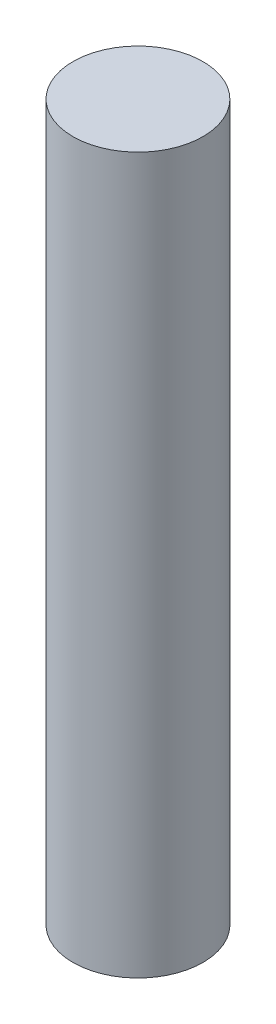
from build123d import *

# Parameters (mm, degrees)
SKETCH1_R           = 3.175
BOSS_EXTRUDE1_DEPTH = 34.925


with BuildPart() as part:
    # Sketch1 → Boss-Extrude1 (new body)
    with BuildSketch(Plane(origin=(0, 0, 0), x_dir=(1, 0, 0), z_dir=(0, 1, 0))):
        Circle(SKETCH1_R)
    extrude(amount=BOSS_EXTRUDE1_DEPTH)


solid = part.part
